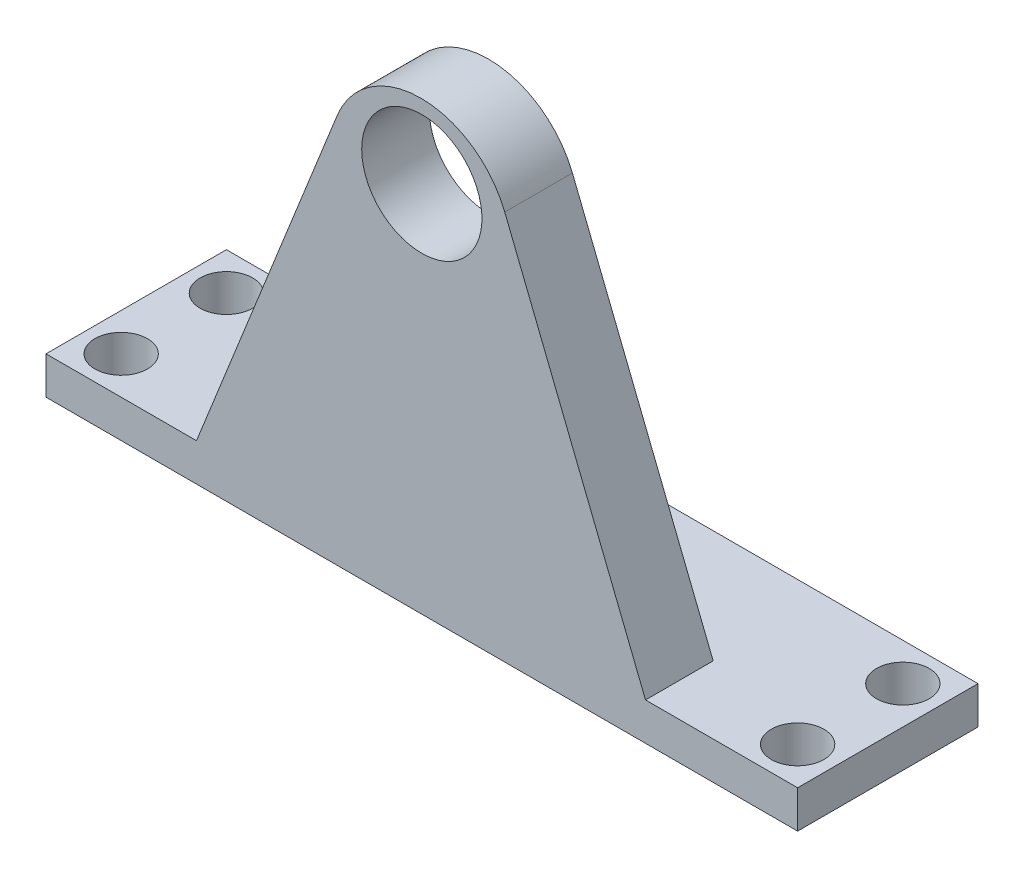
from build123d import *

# Parameters (mm, degrees)
SKETCH1_W           = 100
SKETCH1_H           = 24
SKETCH1_R           = 3.5
BOSS_EXTRUDE1_DEPTH = 5
BOSS_EXTRUDE2_DEPTH = 9
SKETCH3_R           = 8
CUT_EXTRUDE1_DEPTH  = 10


with BuildPart() as part:
    # Sketch1 → Boss-Extrude1 (new body)
    with BuildSketch(Plane(origin=(0, 0, 0), x_dir=(1, 0, 0), z_dir=(0, 1, 0))):
        Rectangle(SKETCH1_W, SKETCH1_H)
        with Locations((-45, 7)):
            Circle(SKETCH1_R, mode=Mode.SUBTRACT)
        with Locations((-45, -7)):
            Circle(SKETCH1_R, mode=Mode.SUBTRACT)
        with Locations((45, 7)):
            Circle(SKETCH1_R, mode=Mode.SUBTRACT)
        with Locations((45, -7)):
            Circle(SKETCH1_R, mode=Mode.SUBTRACT)
    extrude(amount=BOSS_EXTRUDE1_DEPTH)

    # Sketch2 → Boss-Extrude2 (add)
    with BuildSketch(Plane.XY.offset(3)):
        with BuildLine():
            Line((-29.978021695, 5), (29.763516014, 5))
            Line((29.763516014, 5), (11.035619534, 51.854874594))
            ThreePointArc((11.035619534, 51.854874594), (-0.107252841, 59.401067767), (-11.250125215, 51.854874594))
            Line((-11.250125215, 51.854874594), (-29.978021695, 5))
        make_face()
    extrude(amount=BOSS_EXTRUDE2_DEPTH)

    # Sketch3 → Cut-Extrude1 (cut, through all)
    with BuildSketch(Plane(origin=(0, 0, 3), x_dir=(-1, 0, 0), z_dir=(0, 0, -1))):
        with Locations((0, 49.578279074)):
            Circle(SKETCH3_R)
    extrude(amount=-CUT_EXTRUDE1_DEPTH, mode=Mode.SUBTRACT)


solid = part.part
